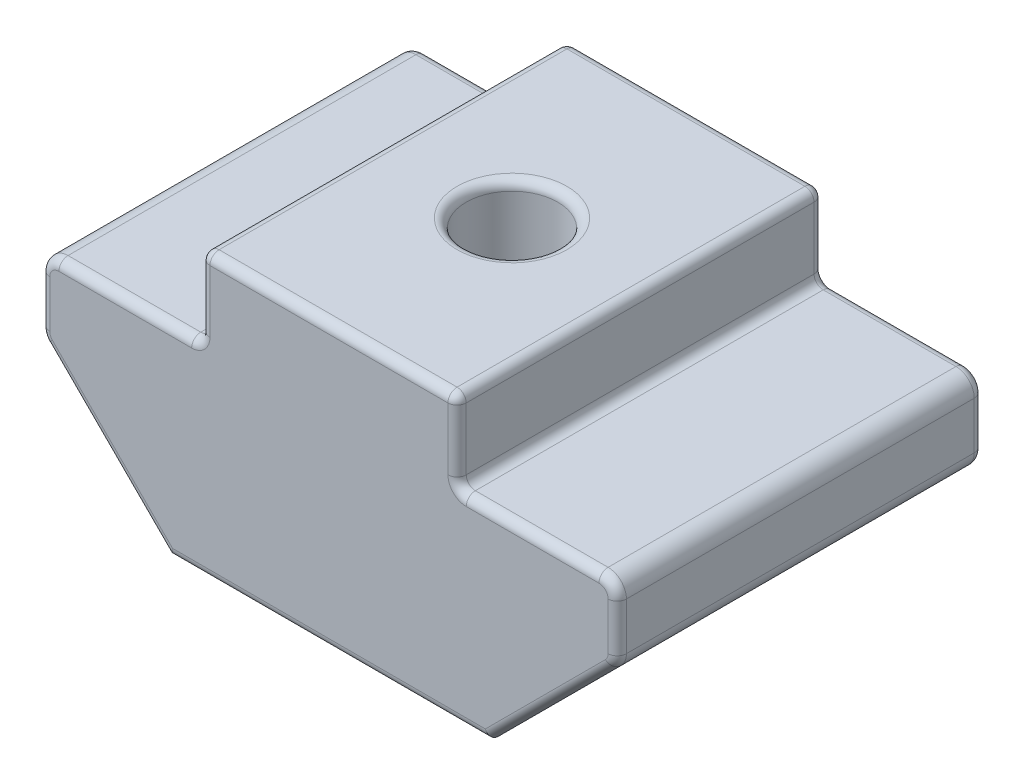
from build123d import *

# Parameters (mm, degrees)
BOSS_EXTRUDE1_DEPTH = 5
SKETCH2_R           = 1.25
CUT_EXTRUDE1_DEPTH  = 8.7
FILLET1_R           = 0.5
FILLET2_R           = 0.25


with BuildPart() as part:
    # Sketch1 → Boss-Extrude1 (new body, symmetric)
    with BuildSketch(Plane.XY):
        Polygon((-4.375, 0), (4.375, 0), (7.875, 3.5), (7.875, 5.5), (3.5, 5.5), (3.5, 7.7), (-3.5, 7.7), (-3.5, 5.5), (-7.875, 5.5), (-7.875, 3.5), align=None)
    extrude(amount=BOSS_EXTRUDE1_DEPTH, both=True)

    # Sketch2 → Cut-Extrude1 (cut, through all)
    with BuildSketch(Plane(origin=(0, 7.7, 0), x_dir=(1, 0, 0), z_dir=(0, 1, 0))):
        Circle(SKETCH2_R)
    extrude(amount=-CUT_EXTRUDE1_DEPTH, mode=Mode.SUBTRACT)

    # Fillet1
    fillet1_edges = [part.edges().sort_by_distance(p)[0] for p in [
        (7.875, 3.5, 0),
        (-7.875, 3.5, 0),
        (-7.875, 5.5, 0),
        (7.875, 5.5, 0),
    ]]
    fillet(fillet1_edges, radius=FILLET1_R)

    # Fillet2
    fillet2_edges = [part.edges().sort_by_distance(p)[0] for p in [
        (3.5, 6.6, 5),
        (-5.4375, 5.5, -5),
        (-3.5, 6.6, -5),
        (0, 7.7, -5),
        (3.5, 6.6, -5),
        (0, 7.7, 5),
        (-3.5, 6.6, 5),
        (-3.5, 5.5, 0),
        (-3.5, 7.7, 0),
        (3.5, 7.7, 0),
        (3.5, 5.5, 0),
        (-5.4375, 5.5, 5),
        (0, 0, 5),
        (-1.25, 7.7, 0),
        (6.051776695, 1.676776695, 5),
        (7.875, 4.353553391, -5),
        (7.875, 4.353553391, 5),
        (-6.051776695, 1.676776695, -5),
        (-7.875, 4.353553391, -5),
        (5.4375, 5.5, -5),
        (-7.728553391, 5.353553391, -5),
        (-7.836939766, 3.515765065, -5),
        (7.728553391, 5.353553391, -5),
        (7.836939766, 3.515765065, -5),
        (5.4375, 5.5, 5),
        (-7.875, 4.353553391, 5),
        (-6.051776695, 1.676776695, 5),
        (-7.728553391, 5.353553391, 5),
        (-7.836939766, 3.515765065, 5),
        (7.728553391, 5.353553391, 5),
        (7.836939766, 3.515765065, 5),
        (6.051776695, 1.676776695, -5),
        (0, 0, -5),
    ]]
    fillet(fillet2_edges, radius=FILLET2_R)


solid = part.part
